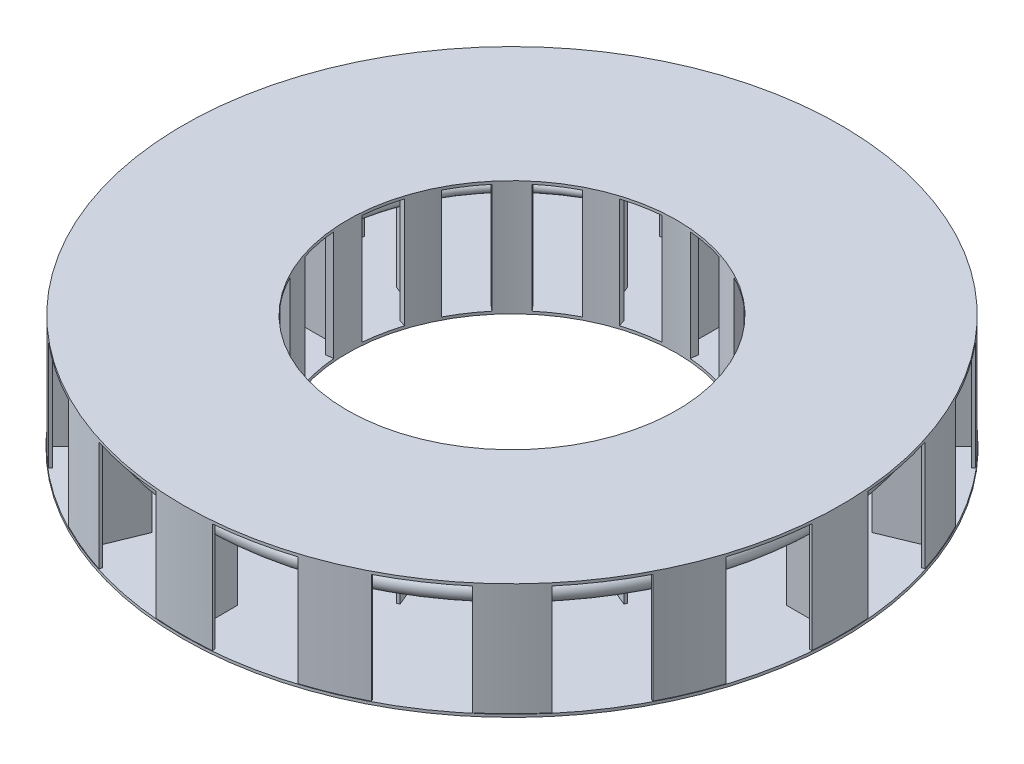
from build123d import *

# Parameters (mm, degrees)
SKETCH1_R           = 9000
SKETCH1_R_2         = 4500
BOSS_EXTRUDE1_DEPTH = 75
BOSS_EXTRUDE5_DEPTH = 3000
SKETCH4_R           = 150
SKETCH4_R_2         = 250
SKETCH7_R           = 8984.476161031
SKETCH7_R_2         = 4500
BOSS_EXTRUDE6_DEPTH = 75


with BuildPart() as part:
    # Sketch1 → Boss-Extrude1 (new body)
    with BuildSketch(Plane(origin=(0, 0, 0), x_dir=(1, 0, 0), z_dir=(0, 1, 0))):
        Circle(SKETCH1_R)
        Circle(SKETCH1_R_2, mode=Mode.SUBTRACT)
    extrude(amount=BOSS_EXTRUDE1_DEPTH)

    # Sketch2 → Boss-Extrude5 (add)
    with BuildSketch(Plane(origin=(0, 75, 0), x_dir=(1, 0, 0), z_dir=(0, 1, 0))):
        with BuildLine():
            Line((-387.610934891, 4483.275338762), (-405.045780921, 4682.51405928))
            ThreePointArc((-405.045780921, 4682.51405928), (-221.44260927, 4694.78041774), (-37.5, 4699.850396555))
            Line((-37.5, 4699.850396555), (-37.5, 5738.315195144))
            Line((-37.5, 5738.315195144), (37.5, 5738.315195144))
            Line((37.5, 5738.315195144), (37.5, 4699.850396555))
            ThreePointArc((37.5, 4699.850396555), (221.44260927, 4694.78041774), (405.045780921, 4682.51405928))
            Line((405.045780921, 4682.51405928), (387.610934891, 4483.275338762))
            ThreePointArc((387.610934891, 4483.275338762), (0, 4500), (-387.610934891, 4483.275338762))
        make_face()
        with BuildLine():
            Line((1357.569385552, 4290.338607081), (1417.70704558, 4481.083209773))
            ThreePointArc((1417.70704558, 4481.083209773), (1592.028390131, 4422.153955373), (1763.909398887, 4356.446215956))
            Line((1763.909398887, 4356.446215956), (2161.312672401, 5315.862588606))
            Line((2161.312672401, 5315.862588606), (2230.60363734, 5287.161331179))
            Line((2230.60363734, 5287.161331179), (1833.200363825, 4327.744958529))
            ThreePointArc((1833.200363825, 4327.744958529), (2001.200978792, 4252.669119798), (2166.134059027, 4171.074590357))
            Line((2166.134059027, 4171.074590357), (2073.781004199, 3993.674041109))
            ThreePointArc((2073.781004199, 3993.674041109), (1722.075445643, 4157.457896301), (1357.569385552, 4290.338607081))
        make_face()
        with BuildLine():
            Line((3368.520012024, 8248.14151143), (2850.142850659, 6978.845747126))
            Line((2850.142850659, 6978.845747126), (2919.433815597, 6950.144489699))
            Line((2919.433815597, 6950.144489699), (3444.124199304, 8216.859130091))
            ThreePointArc((3444.124199304, 8216.859130091), (3774.3212297, 8070.518243522), (4098.315793981, 7910.914809097))
            Line((4098.315793981, 7910.914809097), (4132.815429986, 7977.50891631))
            ThreePointArc((4132.815429986, 7977.50891631), (3436.251875685, 8301.384519162), (2714.568168394, 8564.57421868))
            Line((2714.568168394, 8564.57421868), (2691.907680572, 8493.079447601))
            ThreePointArc((2691.907680572, 8493.079447601), (3032.687686268, 8377.444172392), (3368.520012024, 8248.14151143))
        make_face()
        with BuildLine():
            Line((2896.072073442, 3444.236714489), (3024.626825938, 3597.448062699))
            ThreePointArc((3024.626825938, 3597.448062699), (3163.127498908, 3476.294640225), (3296.779581672, 3349.812590261))
            Line((3296.779581672, 3349.812590261), (4031.085082778, 4084.118091367))
            Line((4031.085082778, 4084.118091367), (4084.118091367, 4031.085082778))
            Line((4084.118091367, 4031.085082778), (3349.812590261, 3296.779581672))
            ThreePointArc((3349.812590261, 3296.779581672), (3476.294640225, 3163.127498908), (3597.448062699, 3024.626825938))
            Line((3597.448062699, 3024.626825938), (3444.236714489, 2896.072073442))
            ThreePointArc((3444.236714489, 2896.072073442), (3181.980515339, 3181.980515339), (2896.072073442, 3444.236714489))
        make_face()
        with BuildLine():
            Line((6268.533798191, 6331.212323475), (5303.877288914, 5356.910297503))
            Line((5303.877288914, 5356.910297503), (5356.910297503, 5303.877288914))
            Line((5356.910297503, 5303.877288914), (6326.411710327, 6273.378701738))
            ThreePointArc((6326.411710327, 6273.378701738), (6575.471755639, 6011.816418919), (6813.72611212, 5740.374720609))
            Line((6813.72611212, 5740.374720609), (6871.084081228, 5788.697214127))
            ThreePointArc((6871.084081228, 5788.697214127), (6351.485097675, 6354.482586502), (5785.454629136, 6873.814561243))
            Line((5785.454629136, 6873.814561243), (5737.159203848, 6816.433798819))
            ThreePointArc((5737.159203848, 6816.433798819), (6007.74717218, 6579.189872557), (6268.533798191, 6331.212323475))
        make_face()
        with BuildLine():
            Line((-44.320410264, 8909.365923859), (-37.5, 7538.315195144))
            Line((-37.5, 7538.315195144), (37.5, 7538.315195144))
            Line((37.5, 7538.315195144), (37.5, 8909.397241901))
            ThreePointArc((37.5, 8909.397241901), (398.564510846, 8900.556824979), (758.974047534, 8877.089830522))
            Line((758.974047534, 8877.089830522), (765.363093594, 8951.817202284))
            ThreePointArc((765.363093594, 8951.817202284), (-2.119544676, 8984.475911018), (-769.586688364, 8951.455089383))
            Line((-769.586688364, 8951.455089383), (-763.162384867, 8876.730740442))
            ThreePointArc((-763.162384867, 8876.730740442), (-404.071008496, 8900.308538701), (-44.320410264, 8909.365923859))
        make_face()
        with BuildLine():
            Line((3993.674041109, 2073.781004199), (4171.074590357, 2166.134059027))
            ThreePointArc((4171.074590357, 2166.134059027), (4252.669119798, 2001.200978792), (4327.744958529, 1833.200363825))
            Line((4327.744958529, 1833.200363825), (5287.161331179, 2230.60363734))
            Line((5287.161331179, 2230.60363734), (5315.862588606, 2161.312672401))
            Line((5315.862588606, 2161.312672401), (4356.446215956, 1763.909398887))
            ThreePointArc((4356.446215956, 1763.909398887), (4422.153955373, 1592.028390131), (4481.083209773, 1417.70704558))
            Line((4481.083209773, 1417.70704558), (4290.338607081, 1357.569385552))
            ThreePointArc((4290.338607081, 1357.569385552), (4157.457896301, 1722.075445643), (3993.674041109, 2073.781004199))
        make_face()
        with BuildLine():
            Line((8214.220137983, 3450.413451854), (6950.144489699, 2919.433815597))
            Line((6950.144489699, 2919.433815597), (6978.845747126, 2850.142850659))
            Line((6978.845747126, 2850.142850659), (8245.560387518, 3374.833234365))
            ThreePointArc((8245.560387518, 3374.833234365), (8375.566313581, 3037.870041787), (8491.80839627, 2695.914617534))
            Line((8491.80839627, 2695.914617534), (8563.292467635, 2718.608835764))
            ThreePointArc((8563.292467635, 2718.608835764), (8299.762289899, 3440.168283575), (7975.558067869, 4136.57894814))
            Line((7975.558067869, 4136.57894814), (7908.980245816, 4102.047895294))
            ThreePointArc((7908.980245816, 4102.047895294), (8068.181611491, 3779.313555129), (8214.220137983, 3450.413451854))
        make_face()
        with BuildLine():
            Line((4483.275338762, 387.610934891), (4682.51405928, 405.045780921))
            ThreePointArc((4682.51405928, 405.045780921), (4694.78041774, 221.44260927), (4699.850396555, 37.5))
            Line((4699.850396555, 37.5), (5738.315195144, 37.5))
            Line((5738.315195144, 37.5), (5738.315195144, -37.5))
            Line((5738.315195144, -37.5), (4699.850396555, -37.5))
            ThreePointArc((4699.850396555, -37.5), (4694.78041774, -221.44260927), (4682.51405928, -405.045780921))
            Line((4682.51405928, -405.045780921), (4483.275338762, -387.610934891))
            ThreePointArc((4483.275338762, -387.610934891), (4500, 0), (4483.275338762, 387.610934891))
        make_face()
        with BuildLine():
            Line((8909.365923859, 44.320410264), (7538.315195144, 37.5))
            Line((7538.315195144, 37.5), (7538.315195144, -37.5))
            Line((7538.315195144, -37.5), (8909.397241901, -37.5))
            ThreePointArc((8909.397241901, -37.5), (8900.556824979, -398.564510846), (8877.089830522, -758.974047534))
            Line((8877.089830522, -758.974047534), (8951.817202284, -765.363093594))
            ThreePointArc((8951.817202284, -765.363093594), (8984.475911018, 2.119544676), (8951.455089383, 769.586688364))
            Line((8951.455089383, 769.586688364), (8876.730740442, 763.162384867))
            ThreePointArc((8876.730740442, 763.162384867), (8900.308538701, 404.071008496), (8909.365923859, 44.320410264))
        make_face()
        with BuildLine():
            Line((4290.338607081, -1357.569385552), (4481.083209773, -1417.70704558))
            ThreePointArc((4481.083209773, -1417.70704558), (4422.153955373, -1592.028390131), (4356.446215956, -1763.909398887))
            Line((4356.446215956, -1763.909398887), (5315.862588606, -2161.312672401))
            Line((5315.862588606, -2161.312672401), (5287.161331179, -2230.60363734))
            Line((5287.161331179, -2230.60363734), (4327.744958529, -1833.200363825))
            ThreePointArc((4327.744958529, -1833.200363825), (4252.669119798, -2001.200978792), (4171.074590357, -2166.134059027))
            Line((4171.074590357, -2166.134059027), (3993.674041109, -2073.781004199))
            ThreePointArc((3993.674041109, -2073.781004199), (4157.457896301, -1722.075445643), (4290.338607081, -1357.569385552))
        make_face()
        with BuildLine():
            Line((8248.14151143, -3368.520012024), (6978.845747126, -2850.142850659))
            Line((6978.845747126, -2850.142850659), (6950.144489699, -2919.433815597))
            Line((6950.144489699, -2919.433815597), (8216.859130091, -3444.124199304))
            ThreePointArc((8216.859130091, -3444.124199304), (8070.518243522, -3774.3212297), (7910.914809097, -4098.315793981))
            Line((7910.914809097, -4098.315793981), (7977.50891631, -4132.815429986))
            ThreePointArc((7977.50891631, -4132.815429986), (8301.384519162, -3436.251875685), (8564.57421868, -2714.568168394))
            Line((8564.57421868, -2714.568168394), (8493.079447601, -2691.907680572))
            ThreePointArc((8493.079447601, -2691.907680572), (8377.444172392, -3032.687686268), (8248.14151143, -3368.520012024))
        make_face()
        with BuildLine():
            Line((3444.236714489, -2896.072073442), (3597.448062699, -3024.626825938))
            ThreePointArc((3597.448062699, -3024.626825938), (3476.294640225, -3163.127498908), (3349.812590261, -3296.779581672))
            Line((3349.812590261, -3296.779581672), (4084.118091367, -4031.085082778))
            Line((4084.118091367, -4031.085082778), (4031.085082778, -4084.118091367))
            Line((4031.085082778, -4084.118091367), (3296.779581672, -3349.812590261))
            ThreePointArc((3296.779581672, -3349.812590261), (3163.127498908, -3476.294640225), (3024.626825938, -3597.448062699))
            Line((3024.626825938, -3597.448062699), (2896.072073442, -3444.236714489))
            ThreePointArc((2896.072073442, -3444.236714489), (3181.980515339, -3181.980515339), (3444.236714489, -2896.072073442))
        make_face()
        with BuildLine():
            Line((6331.212323475, -6268.533798191), (5356.910297503, -5303.877288914))
            Line((5356.910297503, -5303.877288914), (5303.877288914, -5356.910297503))
            Line((5303.877288914, -5356.910297503), (6273.378701738, -6326.411710327))
            ThreePointArc((6273.378701738, -6326.411710327), (6011.816418919, -6575.471755639), (5740.374720609, -6813.72611212))
            Line((5740.374720609, -6813.72611212), (5788.697214127, -6871.084081228))
            ThreePointArc((5788.697214127, -6871.084081228), (6354.482586502, -6351.485097675), (6873.814561243, -5785.454629136))
            Line((6873.814561243, -5785.454629136), (6816.433798819, -5737.159203848))
            ThreePointArc((6816.433798819, -5737.159203848), (6579.189872557, -6007.74717218), (6331.212323475, -6268.533798191))
        make_face()
        with BuildLine():
            Line((2073.781004199, -3993.674041109), (2166.134059027, -4171.074590357))
            ThreePointArc((2166.134059027, -4171.074590357), (2001.200978792, -4252.669119798), (1833.200363825, -4327.744958529))
            Line((1833.200363825, -4327.744958529), (2230.60363734, -5287.161331179))
            Line((2230.60363734, -5287.161331179), (2161.312672401, -5315.862588606))
            Line((2161.312672401, -5315.862588606), (1763.909398887, -4356.446215956))
            ThreePointArc((1763.909398887, -4356.446215956), (1592.028390131, -4422.153955373), (1417.70704558, -4481.083209773))
            Line((1417.70704558, -4481.083209773), (1357.569385552, -4290.338607081))
            ThreePointArc((1357.569385552, -4290.338607081), (1722.075445643, -4157.457896301), (2073.781004199, -3993.674041109))
        make_face()
        with BuildLine():
            Line((3450.413451854, -8214.220137983), (2919.433815597, -6950.144489699))
            Line((2919.433815597, -6950.144489699), (2850.142850659, -6978.845747126))
            Line((2850.142850659, -6978.845747126), (3374.833234365, -8245.560387518))
            ThreePointArc((3374.833234365, -8245.560387518), (3037.870041787, -8375.566313581), (2695.914617534, -8491.80839627))
            Line((2695.914617534, -8491.80839627), (2718.608835764, -8563.292467635))
            ThreePointArc((2718.608835764, -8563.292467635), (3440.168283575, -8299.762289899), (4136.57894814, -7975.558067869))
            Line((4136.57894814, -7975.558067869), (4102.047895294, -7908.980245816))
            ThreePointArc((4102.047895294, -7908.980245816), (3779.313555129, -8068.181611491), (3450.413451854, -8214.220137983))
        make_face()
        with BuildLine():
            Line((387.610934891, -4483.275338762), (405.045780921, -4682.51405928))
            ThreePointArc((405.045780921, -4682.51405928), (221.44260927, -4694.78041774), (37.5, -4699.850396555))
            Line((37.5, -4699.850396555), (37.5, -5738.315195144))
            Line((37.5, -5738.315195144), (-37.5, -5738.315195144))
            Line((-37.5, -5738.315195144), (-37.5, -4699.850396555))
            ThreePointArc((-37.5, -4699.850396555), (-221.44260927, -4694.78041774), (-405.045780921, -4682.51405928))
            Line((-405.045780921, -4682.51405928), (-387.610934891, -4483.275338762))
            ThreePointArc((-387.610934891, -4483.275338762), (0, -4500), (387.610934891, -4483.275338762))
        make_face()
        with BuildLine():
            Line((44.320410264, -8909.365923859), (37.5, -7538.315195144))
            Line((37.5, -7538.315195144), (-37.5, -7538.315195144))
            Line((-37.5, -7538.315195144), (-37.5, -8909.397241901))
            ThreePointArc((-37.5, -8909.397241901), (-398.564510846, -8900.556824979), (-758.974047534, -8877.089830522))
            Line((-758.974047534, -8877.089830522), (-765.363093594, -8951.817202284))
            ThreePointArc((-765.363093594, -8951.817202284), (2.119544676, -8984.475911018), (769.586688364, -8951.455089383))
            Line((769.586688364, -8951.455089383), (763.162384867, -8876.730740442))
            ThreePointArc((763.162384867, -8876.730740442), (404.071008496, -8900.308538701), (44.320410264, -8909.365923859))
        make_face()
        with BuildLine():
            Line((-1357.569385552, -4290.338607081), (-1417.70704558, -4481.083209773))
            ThreePointArc((-1417.70704558, -4481.083209773), (-1592.028390131, -4422.153955373), (-1763.909398887, -4356.446215956))
            Line((-1763.909398887, -4356.446215956), (-2161.312672401, -5315.862588606))
            Line((-2161.312672401, -5315.862588606), (-2230.60363734, -5287.161331179))
            Line((-2230.60363734, -5287.161331179), (-1833.200363825, -4327.744958529))
            ThreePointArc((-1833.200363825, -4327.744958529), (-2001.200978792, -4252.669119798), (-2166.134059027, -4171.074590357))
            Line((-2166.134059027, -4171.074590357), (-2073.781004199, -3993.674041109))
            ThreePointArc((-2073.781004199, -3993.674041109), (-1722.075445643, -4157.457896301), (-1357.569385552, -4290.338607081))
        make_face()
        with BuildLine():
            Line((-3368.520012024, -8248.14151143), (-2850.142850659, -6978.845747126))
            Line((-2850.142850659, -6978.845747126), (-2919.433815597, -6950.144489699))
            Line((-2919.433815597, -6950.144489699), (-3444.124199304, -8216.859130091))
            ThreePointArc((-3444.124199304, -8216.859130091), (-3774.3212297, -8070.518243522), (-4098.315793981, -7910.914809097))
            Line((-4098.315793981, -7910.914809097), (-4132.815429986, -7977.50891631))
            ThreePointArc((-4132.815429986, -7977.50891631), (-3436.251875685, -8301.384519162), (-2714.568168394, -8564.57421868))
            Line((-2714.568168394, -8564.57421868), (-2691.907680572, -8493.079447601))
            ThreePointArc((-2691.907680572, -8493.079447601), (-3032.687686268, -8377.444172392), (-3368.520012024, -8248.14151143))
        make_face()
        with BuildLine():
            Line((-2896.072073442, -3444.236714489), (-3024.626825938, -3597.448062699))
            ThreePointArc((-3024.626825938, -3597.448062699), (-3163.127498908, -3476.294640225), (-3296.779581672, -3349.812590261))
            Line((-3296.779581672, -3349.812590261), (-4031.085082778, -4084.118091367))
            Line((-4031.085082778, -4084.118091367), (-4084.118091367, -4031.085082778))
            Line((-4084.118091367, -4031.085082778), (-3349.812590261, -3296.779581672))
            ThreePointArc((-3349.812590261, -3296.779581672), (-3476.294640225, -3163.127498908), (-3597.448062699, -3024.626825938))
            Line((-3597.448062699, -3024.626825938), (-3444.236714489, -2896.072073442))
            ThreePointArc((-3444.236714489, -2896.072073442), (-3181.980515339, -3181.980515339), (-2896.072073442, -3444.236714489))
        make_face()
        with BuildLine():
            Line((-6268.533798191, -6331.212323475), (-5303.877288914, -5356.910297503))
            Line((-5303.877288914, -5356.910297503), (-5356.910297503, -5303.877288914))
            Line((-5356.910297503, -5303.877288914), (-6326.411710327, -6273.378701738))
            ThreePointArc((-6326.411710327, -6273.378701738), (-6575.471755639, -6011.816418919), (-6813.72611212, -5740.374720609))
            Line((-6813.72611212, -5740.374720609), (-6871.084081228, -5788.697214127))
            ThreePointArc((-6871.084081228, -5788.697214127), (-6351.485097675, -6354.482586502), (-5785.454629136, -6873.814561243))
            Line((-5785.454629136, -6873.814561243), (-5737.159203848, -6816.433798819))
            ThreePointArc((-5737.159203848, -6816.433798819), (-6007.74717218, -6579.189872557), (-6268.533798191, -6331.212323475))
        make_face()
        with BuildLine():
            Line((-3993.674041109, -2073.781004199), (-4171.074590357, -2166.134059027))
            ThreePointArc((-4171.074590357, -2166.134059027), (-4252.669119798, -2001.200978792), (-4327.744958529, -1833.200363825))
            Line((-4327.744958529, -1833.200363825), (-5287.161331179, -2230.60363734))
            Line((-5287.161331179, -2230.60363734), (-5315.862588606, -2161.312672401))
            Line((-5315.862588606, -2161.312672401), (-4356.446215956, -1763.909398887))
            ThreePointArc((-4356.446215956, -1763.909398887), (-4422.153955373, -1592.028390131), (-4481.083209773, -1417.70704558))
            Line((-4481.083209773, -1417.70704558), (-4290.338607081, -1357.569385552))
            ThreePointArc((-4290.338607081, -1357.569385552), (-4157.457896301, -1722.075445643), (-3993.674041109, -2073.781004199))
        make_face()
        with BuildLine():
            Line((-8214.220137983, -3450.413451854), (-6950.144489699, -2919.433815597))
            Line((-6950.144489699, -2919.433815597), (-6978.845747126, -2850.142850659))
            Line((-6978.845747126, -2850.142850659), (-8245.560387518, -3374.833234365))
            ThreePointArc((-8245.560387518, -3374.833234365), (-8375.566313581, -3037.870041787), (-8491.80839627, -2695.914617534))
            Line((-8491.80839627, -2695.914617534), (-8563.292467635, -2718.608835764))
            ThreePointArc((-8563.292467635, -2718.608835764), (-8299.762289899, -3440.168283575), (-7975.558067869, -4136.57894814))
            Line((-7975.558067869, -4136.57894814), (-7908.980245816, -4102.047895294))
            ThreePointArc((-7908.980245816, -4102.047895294), (-8068.181611491, -3779.313555129), (-8214.220137983, -3450.413451854))
        make_face()
        with BuildLine():
            Line((-4483.275338762, -387.610934891), (-4682.51405928, -405.045780921))
            ThreePointArc((-4682.51405928, -405.045780921), (-4694.78041774, -221.44260927), (-4699.850396555, -37.5))
            Line((-4699.850396555, -37.5), (-5738.315195144, -37.5))
            Line((-5738.315195144, -37.5), (-5738.315195144, 37.5))
            Line((-5738.315195144, 37.5), (-4699.850396555, 37.5))
            ThreePointArc((-4699.850396555, 37.5), (-4694.78041774, 221.44260927), (-4682.51405928, 405.045780921))
            Line((-4682.51405928, 405.045780921), (-4483.275338762, 387.610934891))
            ThreePointArc((-4483.275338762, 387.610934891), (-4500, 0), (-4483.275338762, -387.610934891))
        make_face()
        with BuildLine():
            Line((-8909.365923859, -44.320410264), (-7538.315195144, -37.5))
            Line((-7538.315195144, -37.5), (-7538.315195144, 37.5))
            Line((-7538.315195144, 37.5), (-8909.397241901, 37.5))
            ThreePointArc((-8909.397241901, 37.5), (-8900.556824979, 398.564510846), (-8877.089830522, 758.974047534))
            Line((-8877.089830522, 758.974047534), (-8951.817202284, 765.363093594))
            ThreePointArc((-8951.817202284, 765.363093594), (-8984.475911018, -2.119544676), (-8951.455089383, -769.586688364))
            Line((-8951.455089383, -769.586688364), (-8876.730740442, -763.162384867))
            ThreePointArc((-8876.730740442, -763.162384867), (-8900.308538701, -404.071008496), (-8909.365923859, -44.320410264))
        make_face()
        with BuildLine():
            Line((-4290.338607081, 1357.569385552), (-4481.083209773, 1417.70704558))
            ThreePointArc((-4481.083209773, 1417.70704558), (-4422.153955373, 1592.028390131), (-4356.446215956, 1763.909398887))
            Line((-4356.446215956, 1763.909398887), (-5315.862588606, 2161.312672401))
            Line((-5315.862588606, 2161.312672401), (-5287.161331179, 2230.60363734))
            Line((-5287.161331179, 2230.60363734), (-4327.744958529, 1833.200363825))
            ThreePointArc((-4327.744958529, 1833.200363825), (-4252.669119798, 2001.200978792), (-4171.074590357, 2166.134059027))
            Line((-4171.074590357, 2166.134059027), (-3993.674041109, 2073.781004199))
            ThreePointArc((-3993.674041109, 2073.781004199), (-4157.457896301, 1722.075445643), (-4290.338607081, 1357.569385552))
        make_face()
        with BuildLine():
            Line((-8248.14151143, 3368.520012024), (-6978.845747126, 2850.142850659))
            Line((-6978.845747126, 2850.142850659), (-6950.144489699, 2919.433815597))
            Line((-6950.144489699, 2919.433815597), (-8216.859130091, 3444.124199304))
            ThreePointArc((-8216.859130091, 3444.124199304), (-8070.518243522, 3774.3212297), (-7910.914809097, 4098.315793981))
            Line((-7910.914809097, 4098.315793981), (-7977.50891631, 4132.815429986))
            ThreePointArc((-7977.50891631, 4132.815429986), (-8301.384519162, 3436.251875685), (-8564.57421868, 2714.568168394))
            Line((-8564.57421868, 2714.568168394), (-8493.079447601, 2691.907680572))
            ThreePointArc((-8493.079447601, 2691.907680572), (-8377.444172392, 3032.687686268), (-8248.14151143, 3368.520012024))
        make_face()
        with BuildLine():
            Line((-3444.236714489, 2896.072073442), (-3597.448062699, 3024.626825938))
            ThreePointArc((-3597.448062699, 3024.626825938), (-3476.294640225, 3163.127498908), (-3349.812590261, 3296.779581672))
            Line((-3349.812590261, 3296.779581672), (-4084.118091367, 4031.085082778))
            Line((-4084.118091367, 4031.085082778), (-4031.085082778, 4084.118091367))
            Line((-4031.085082778, 4084.118091367), (-3296.779581672, 3349.812590261))
            ThreePointArc((-3296.779581672, 3349.812590261), (-3163.127498908, 3476.294640225), (-3024.626825938, 3597.448062699))
            Line((-3024.626825938, 3597.448062699), (-2896.072073442, 3444.236714489))
            ThreePointArc((-2896.072073442, 3444.236714489), (-3181.980515339, 3181.980515339), (-3444.236714489, 2896.072073442))
        make_face()
        with BuildLine():
            Line((-6331.212323475, 6268.533798191), (-5356.910297503, 5303.877288914))
            Line((-5356.910297503, 5303.877288914), (-5303.877288914, 5356.910297503))
            Line((-5303.877288914, 5356.910297503), (-6273.378701738, 6326.411710327))
            ThreePointArc((-6273.378701738, 6326.411710327), (-6011.816418919, 6575.471755639), (-5740.374720609, 6813.72611212))
            Line((-5740.374720609, 6813.72611212), (-5788.697214127, 6871.084081228))
            ThreePointArc((-5788.697214127, 6871.084081228), (-6354.482586502, 6351.485097675), (-6873.814561243, 5785.454629136))
            Line((-6873.814561243, 5785.454629136), (-6816.433798819, 5737.159203848))
            ThreePointArc((-6816.433798819, 5737.159203848), (-6579.189872557, 6007.74717218), (-6331.212323475, 6268.533798191))
        make_face()
        with BuildLine():
            Line((-2073.781004199, 3993.674041109), (-2166.134059027, 4171.074590357))
            ThreePointArc((-2166.134059027, 4171.074590357), (-2001.200978792, 4252.669119798), (-1833.200363825, 4327.744958529))
            Line((-1833.200363825, 4327.744958529), (-2230.60363734, 5287.161331179))
            Line((-2230.60363734, 5287.161331179), (-2161.312672401, 5315.862588606))
            Line((-2161.312672401, 5315.862588606), (-1763.909398887, 4356.446215956))
            ThreePointArc((-1763.909398887, 4356.446215956), (-1592.028390131, 4422.153955373), (-1417.70704558, 4481.083209773))
            Line((-1417.70704558, 4481.083209773), (-1357.569385552, 4290.338607081))
            ThreePointArc((-1357.569385552, 4290.338607081), (-1722.075445643, 4157.457896301), (-2073.781004199, 3993.674041109))
        make_face()
        with BuildLine():
            Line((-3450.413451854, 8214.220137983), (-2919.433815597, 6950.144489699))
            Line((-2919.433815597, 6950.144489699), (-2850.142850659, 6978.845747126))
            Line((-2850.142850659, 6978.845747126), (-3374.833234365, 8245.560387518))
            ThreePointArc((-3374.833234365, 8245.560387518), (-3037.870041787, 8375.566313581), (-2695.914617534, 8491.80839627))
            Line((-2695.914617534, 8491.80839627), (-2718.608835764, 8563.292467635))
            ThreePointArc((-2718.608835764, 8563.292467635), (-3440.168283575, 8299.762289899), (-4136.57894814, 7975.558067869))
            Line((-4136.57894814, 7975.558067869), (-4102.047895294, 7908.980245816))
            ThreePointArc((-4102.047895294, 7908.980245816), (-3779.313555129, 8068.181611491), (-3450.413451854, 8214.220137983))
        make_face()
    extrude(amount=BOSS_EXTRUDE5_DEPTH)

    # Sweep3: sweep along a path in Sketch5
    with BuildLine(Plane(origin=(0, 2500, 0), x_dir=(1, 0, 0), z_dir=(0, 1, 0))) as sweep3_path:
        ThreePointArc((-3119.814309661, 7629.890240835), (1609.865320569, -8084.355265794), (-41.005435753, 8242.983984467))
    # Sketch4 → Sweep3 (sweep)
    with BuildSketch(Plane(origin=(0, 0, 0), x_dir=(0, 0, -1), z_dir=(1, 0, 0))):
        with Locations((-5287.161331179, 2500)):
            Circle(SKETCH4_R)
        with Locations((-8243.085976377, 2500)):
            Circle(SKETCH4_R_2)
    sweep(path=sweep3_path.line)

    # Sketch7 → Boss-Extrude6 (add)
    with BuildSketch(Plane(origin=(0, 3075, 0), x_dir=(1, 0, 0), z_dir=(0, 1, 0))):
        Circle(SKETCH7_R)
        Circle(SKETCH7_R_2, mode=Mode.SUBTRACT)
    extrude(amount=BOSS_EXTRUDE6_DEPTH)


solid = part.part
